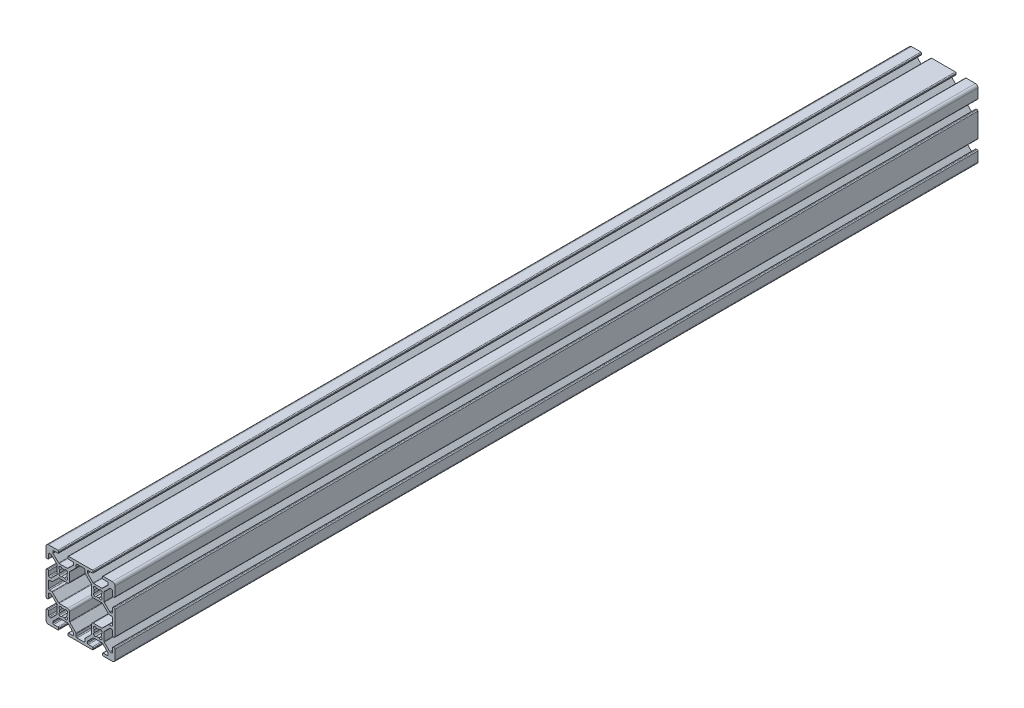
from build123d import *

# Parameters (mm, degrees)
EXTRUDE1_DEPTH = 500


with BuildPart() as part:
    # Sketch1 → Extrude1 (new body)
    with BuildSketch(Plane.XY):
        with BuildLine():
            Line((-22.383919339, -3.655), (-17.616080661, -3.655))
            ThreePointArc((-17.616080661, -3.655), (-17.421677478, -3.693669197), (-17.256870417, -3.803789755))
            Line((-17.256870417, -3.803789755), (-14.153789755, -6.906870417))
            ThreePointArc((-14.153789755, -6.906870417), (-14.043669197, -7.071677478), (-14.005, -7.266080661))
            Line((-14.005, -7.266080661), (-14.005, -7.992))
            ThreePointArc((-14.005, -7.992), (-14.153789755, -8.351210245), (-14.513, -8.5))
            Line((-14.513, -8.5), (-16.862, -8.5))
            ThreePointArc((-16.862, -8.5), (-17.221210245, -8.648789755), (-17.37, -9.008))
            Line((-17.37, -9.008), (-17.37, -9.492))
            ThreePointArc((-17.37, -9.492), (-17.221210245, -9.851210245), (-16.862, -10))
            Line((-16.862, -10), (-3.138, -10))
            ThreePointArc((-3.138, -10), (-2.778789755, -9.851210245), (-2.63, -9.492))
            Line((-2.63, -9.492), (-2.63, -9.008))
            ThreePointArc((-2.63, -9.008), (-2.778789755, -8.648789755), (-3.138, -8.5))
            Line((-3.138, -8.5), (-5.487, -8.5))
            ThreePointArc((-5.487, -8.5), (-5.846210245, -8.351210245), (-5.995, -7.992))
            Line((-5.995, -7.992), (-5.995, -7.266080661))
            ThreePointArc((-5.995, -7.266080661), (-5.956330803, -7.071677478), (-5.846210245, -6.906870417))
            Line((-5.846210245, -6.906870417), (-2.743129583, -3.803789755))
            ThreePointArc((-2.743129583, -3.803789755), (-2.578322522, -3.693669197), (-2.383919339, -3.655))
            Line((-2.383919339, -3.655), (2.383919339, -3.655))
            ThreePointArc((2.383919339, -3.655), (2.578322522, -3.693669197), (2.743129583, -3.803789755))
            Line((2.743129583, -3.803789755), (5.846210245, -6.906870417))
            ThreePointArc((5.846210245, -6.906870417), (5.956330803, -7.071677478), (5.995, -7.266080661))
            Line((5.995, -7.266080661), (5.995, -7.992))
            ThreePointArc((5.995, -7.992), (5.846210245, -8.351210245), (5.487, -8.5))
            Line((5.487, -8.5), (3.138, -8.5))
            ThreePointArc((3.138, -8.5), (2.778789755, -8.648789755), (2.63, -9.008))
            Line((2.63, -9.008), (2.63, -9.492))
            ThreePointArc((2.63, -9.492), (2.778789755, -9.851210245), (3.138, -10))
            Line((3.138, -10), (8.5, -10))
            ThreePointArc((8.5, -10), (9.560660172, -9.560660172), (10, -8.5))
            Line((10, -8.5), (10, -3.138))
            ThreePointArc((10, -3.138), (9.851210245, -2.778789755), (9.492, -2.63))
            Line((9.492, -2.63), (9.008, -2.63))
            ThreePointArc((9.008, -2.63), (8.648789755, -2.778789755), (8.5, -3.138))
            Line((8.5, -3.138), (8.5, -5.487))
            ThreePointArc((8.5, -5.487), (8.351210245, -5.846210245), (7.992, -5.995))
            Line((7.992, -5.995), (7.266080661, -5.995))
            ThreePointArc((7.266080661, -5.995), (7.071677478, -5.956330803), (6.906870417, -5.846210245))
            Line((6.906870417, -5.846210245), (3.803789755, -2.743129583))
            ThreePointArc((3.803789755, -2.743129583), (3.693669197, -2.578322522), (3.655, -2.383919339))
            Line((3.655, -2.383919339), (3.655, 2.383919339))
            ThreePointArc((3.655, 2.383919339), (3.693669197, 2.578322522), (3.803789755, 2.743129583))
            Line((3.803789755, 2.743129583), (6.906870417, 5.846210245))
            ThreePointArc((6.906870417, 5.846210245), (7.071677478, 5.956330803), (7.266080661, 5.995))
            Line((7.266080661, 5.995), (7.992, 5.995))
            ThreePointArc((7.992, 5.995), (8.351210245, 5.846210245), (8.5, 5.487))
            Line((8.5, 5.487), (8.5, 3.138))
            ThreePointArc((8.5, 3.138), (8.648789755, 2.778789755), (9.008, 2.63))
            Line((9.008, 2.63), (9.492, 2.63))
            ThreePointArc((9.492, 2.63), (9.851210245, 2.778789755), (10, 3.138))
            Line((10, 3.138), (10, 16.862))
            ThreePointArc((10, 16.862), (9.851210245, 17.221210245), (9.492, 17.37))
            Line((9.492, 17.37), (9.008, 17.37))
            ThreePointArc((9.008, 17.37), (8.648789755, 17.221210245), (8.5, 16.862))
            Line((8.5, 16.862), (8.5, 14.513))
            ThreePointArc((8.5, 14.513), (8.351210245, 14.153789755), (7.992, 14.005))
            Line((7.992, 14.005), (7.266080661, 14.005))
            ThreePointArc((7.266080661, 14.005), (7.071677478, 14.043669197), (6.906870417, 14.153789755))
            Line((6.906870417, 14.153789755), (3.803789755, 17.256870417))
            ThreePointArc((3.803789755, 17.256870417), (3.693669197, 17.421677478), (3.655, 17.616080661))
            Line((3.655, 17.616080661), (3.655, 22.383919339))
            ThreePointArc((3.655, 22.383919339), (3.693669197, 22.578322522), (3.803789755, 22.743129583))
            Line((3.803789755, 22.743129583), (6.906870417, 25.846210245))
            ThreePointArc((6.906870417, 25.846210245), (7.071677478, 25.956330803), (7.266080661, 25.995))
            Line((7.266080661, 25.995), (7.992, 25.995))
            ThreePointArc((7.992, 25.995), (8.351210245, 25.846210245), (8.5, 25.487))
            Line((8.5, 25.487), (8.5, 23.138))
            ThreePointArc((8.5, 23.138), (8.648789755, 22.778789755), (9.008, 22.63))
            Line((9.008, 22.63), (9.492, 22.63))
            ThreePointArc((9.492, 22.63), (9.851210245, 22.778789755), (10, 23.138))
            Line((10, 23.138), (10, 28.5))
            ThreePointArc((10, 28.5), (9.560660172, 29.560660172), (8.5, 30))
            Line((8.5, 30), (3.138, 30))
            ThreePointArc((3.138, 30), (2.778789755, 29.851210245), (2.63, 29.492))
            Line((2.63, 29.492), (2.63, 29.008))
            ThreePointArc((2.63, 29.008), (2.778789755, 28.648789755), (3.138, 28.5))
            Line((3.138, 28.5), (5.487, 28.5))
            ThreePointArc((5.487, 28.5), (5.846210245, 28.351210245), (5.995, 27.992))
            Line((5.995, 27.992), (5.995, 27.266080661))
            ThreePointArc((5.995, 27.266080661), (5.956330803, 27.071677478), (5.846210245, 26.906870417))
            Line((5.846210245, 26.906870417), (2.743129583, 23.803789755))
            ThreePointArc((2.743129583, 23.803789755), (2.578322522, 23.693669197), (2.383919339, 23.655))
            Line((2.383919339, 23.655), (-2.383919339, 23.655))
            ThreePointArc((-2.383919339, 23.655), (-2.578322522, 23.693669197), (-2.743129583, 23.803789755))
            Line((-2.743129583, 23.803789755), (-5.846210245, 26.906870417))
            ThreePointArc((-5.846210245, 26.906870417), (-5.956330803, 27.071677478), (-5.995, 27.266080661))
            Line((-5.995, 27.266080661), (-5.995, 27.992))
            ThreePointArc((-5.995, 27.992), (-5.846210245, 28.351210245), (-5.487, 28.5))
            Line((-5.487, 28.5), (-3.138, 28.5))
            ThreePointArc((-3.138, 28.5), (-2.778789755, 28.648789755), (-2.63, 29.008))
            Line((-2.63, 29.008), (-2.63, 29.492))
            ThreePointArc((-2.63, 29.492), (-2.778789755, 29.851210245), (-3.138, 30))
            Line((-3.138, 30), (-16.862, 30))
            ThreePointArc((-16.862, 30), (-17.221210245, 29.851210245), (-17.37, 29.492))
            Line((-17.37, 29.492), (-17.37, 29.008))
            ThreePointArc((-17.37, 29.008), (-17.221210245, 28.648789755), (-16.862, 28.5))
            Line((-16.862, 28.5), (-14.513, 28.5))
            ThreePointArc((-14.513, 28.5), (-14.153789755, 28.351210245), (-14.005, 27.992))
            Line((-14.005, 27.992), (-14.005, 27.266080661))
            ThreePointArc((-14.005, 27.266080661), (-14.043669197, 27.071677478), (-14.153789755, 26.906870417))
            Line((-14.153789755, 26.906870417), (-17.256870417, 23.803789755))
            ThreePointArc((-17.256870417, 23.803789755), (-17.421677478, 23.693669197), (-17.616080661, 23.655))
            Line((-17.616080661, 23.655), (-22.383919339, 23.655))
            ThreePointArc((-22.383919339, 23.655), (-22.578322522, 23.693669197), (-22.743129583, 23.803789755))
            Line((-22.743129583, 23.803789755), (-25.846210245, 26.906870417))
            ThreePointArc((-25.846210245, 26.906870417), (-25.956330803, 27.071677478), (-25.995, 27.266080661))
            Line((-25.995, 27.266080661), (-25.995, 27.992))
            ThreePointArc((-25.995, 27.992), (-25.846210245, 28.351210245), (-25.487, 28.5))
            Line((-25.487, 28.5), (-23.138, 28.5))
            ThreePointArc((-23.138, 28.5), (-22.778789755, 28.648789755), (-22.63, 29.008))
            Line((-22.63, 29.008), (-22.63, 29.492))
            ThreePointArc((-22.63, 29.492), (-22.778789755, 29.851210245), (-23.138, 30))
            Line((-23.138, 30), (-28.5, 30))
            ThreePointArc((-28.5, 30), (-29.560660172, 29.560660172), (-30, 28.5))
            Line((-30, 28.5), (-30, 23.138))
            ThreePointArc((-30, 23.138), (-29.851210245, 22.778789755), (-29.492, 22.63))
            Line((-29.492, 22.63), (-29.008, 22.63))
            ThreePointArc((-29.008, 22.63), (-28.648789755, 22.778789755), (-28.5, 23.138))
            Line((-28.5, 23.138), (-28.5, 25.487))
            ThreePointArc((-28.5, 25.487), (-28.351210245, 25.846210245), (-27.992, 25.995))
            Line((-27.992, 25.995), (-27.266080661, 25.995))
            ThreePointArc((-27.266080661, 25.995), (-27.071677478, 25.956330803), (-26.906870417, 25.846210245))
            Line((-26.906870417, 25.846210245), (-23.803789755, 22.743129583))
            ThreePointArc((-23.803789755, 22.743129583), (-23.693669197, 22.578322522), (-23.655, 22.383919339))
            Line((-23.655, 22.383919339), (-23.655, 17.616080661))
            ThreePointArc((-23.655, 17.616080661), (-23.693669197, 17.421677478), (-23.803789755, 17.256870417))
            Line((-23.803789755, 17.256870417), (-26.906870417, 14.153789755))
            ThreePointArc((-26.906870417, 14.153789755), (-27.071677478, 14.043669197), (-27.266080661, 14.005))
            Line((-27.266080661, 14.005), (-27.992, 14.005))
            ThreePointArc((-27.992, 14.005), (-28.351210245, 14.153789755), (-28.5, 14.513))
            Line((-28.5, 14.513), (-28.5, 16.862))
            ThreePointArc((-28.5, 16.862), (-28.648789755, 17.221210245), (-29.008, 17.37))
            Line((-29.008, 17.37), (-29.492, 17.37))
            ThreePointArc((-29.492, 17.37), (-29.851210245, 17.221210245), (-30, 16.862))
            Line((-30, 16.862), (-30, 3.138))
            ThreePointArc((-30, 3.138), (-29.851210245, 2.778789755), (-29.492, 2.63))
            Line((-29.492, 2.63), (-29.008, 2.63))
            ThreePointArc((-29.008, 2.63), (-28.648789755, 2.778789755), (-28.5, 3.138))
            Line((-28.5, 3.138), (-28.5, 5.487))
            ThreePointArc((-28.5, 5.487), (-28.351210245, 5.846210245), (-27.992, 5.995))
            Line((-27.992, 5.995), (-27.266080661, 5.995))
            ThreePointArc((-27.266080661, 5.995), (-27.071677478, 5.956330803), (-26.906870417, 5.846210245))
            Line((-26.906870417, 5.846210245), (-23.803789755, 2.743129583))
            ThreePointArc((-23.803789755, 2.743129583), (-23.693669197, 2.578322522), (-23.655, 2.383919339))
            Line((-23.655, 2.383919339), (-23.655, -2.383919339))
            ThreePointArc((-23.655, -2.383919339), (-23.693669197, -2.578322522), (-23.803789755, -2.743129583))
            Line((-23.803789755, -2.743129583), (-26.906870417, -5.846210245))
            ThreePointArc((-26.906870417, -5.846210245), (-27.071677478, -5.956330803), (-27.266080661, -5.995))
            Line((-27.266080661, -5.995), (-27.992, -5.995))
            ThreePointArc((-27.992, -5.995), (-28.351210245, -5.846210245), (-28.5, -5.487))
            Line((-28.5, -5.487), (-28.5, -3.138))
            ThreePointArc((-28.5, -3.138), (-28.648789755, -2.778789755), (-29.008, -2.63))
            Line((-29.008, -2.63), (-29.492, -2.63))
            ThreePointArc((-29.492, -2.63), (-29.851210245, -2.778789755), (-30, -3.138))
            Line((-30, -3.138), (-30, -8.5))
            ThreePointArc((-30, -8.5), (-29.560660172, -9.560660172), (-28.5, -10))
            Line((-28.5, -10), (-23.138, -10))
            ThreePointArc((-23.138, -10), (-22.778789755, -9.851210245), (-22.63, -9.492))
            Line((-22.63, -9.492), (-22.63, -9.008))
            ThreePointArc((-22.63, -9.008), (-22.778789755, -8.648789755), (-23.138, -8.5))
            Line((-23.138, -8.5), (-25.487, -8.5))
            ThreePointArc((-25.487, -8.5), (-25.846210245, -8.351210245), (-25.995, -7.992))
            Line((-25.995, -7.992), (-25.995, -7.266080661))
            ThreePointArc((-25.995, -7.266080661), (-25.956330803, -7.071677478), (-25.846210245, -6.906870417))
            Line((-25.846210245, -6.906870417), (-22.743129583, -3.803789755))
            ThreePointArc((-22.743129583, -3.803789755), (-22.578322522, -3.693669197), (-22.383919339, -3.655))
        make_face()
        with BuildLine():
            Line((-2.124900844, 17.695494034), (-2.304505966, 17.875099156))
            ThreePointArc((-2.304505966, 17.875099156), (-2.505938017, 18.643532189), (-1.935133506, 19.196023282))
            ThreePointArc((-1.935133506, 19.196023282), (-2.0955, 20), (-1.935133506, 20.803976718))
            ThreePointArc((-1.935133506, 20.803976718), (-2.505938017, 21.356467811), (-2.304505966, 22.124900844))
            Line((-2.304505966, 22.124900844), (-2.124900844, 22.304505966))
            ThreePointArc((-2.124900844, 22.304505966), (-1.356467811, 22.505938017), (-0.803976718, 21.935133506))
            ThreePointArc((-0.803976718, 21.935133506), (0, 22.0955), (0.803976718, 21.935133506))
            ThreePointArc((0.803976718, 21.935133506), (1.356467811, 22.505938017), (2.124900844, 22.304505966))
            Line((2.124900844, 22.304505966), (2.304505966, 22.124900844))
            ThreePointArc((2.304505966, 22.124900844), (2.505938017, 21.356467811), (1.935133506, 20.803976718))
            ThreePointArc((1.935133506, 20.803976718), (2.0955, 20), (1.935133506, 19.196023282))
            ThreePointArc((1.935133506, 19.196023282), (2.505938017, 18.643532189), (2.304505966, 17.875099156))
            Line((2.304505966, 17.875099156), (2.124900844, 17.695494034))
            ThreePointArc((2.124900844, 17.695494034), (1.356467811, 17.494061983), (0.803976718, 18.064866494))
            ThreePointArc((0.803976718, 18.064866494), (0, 17.9045), (-0.803976718, 18.064866494))
            ThreePointArc((-0.803976718, 18.064866494), (-1.356467811, 17.494061983), (-2.124900844, 17.695494034))
        make_face(mode=Mode.SUBTRACT)
        with BuildLine():
            Line((-22.124900844, 17.695494034), (-22.304505966, 17.875099156))
            ThreePointArc((-22.304505966, 17.875099156), (-22.505938017, 18.643532189), (-21.935133506, 19.196023282))
            ThreePointArc((-21.935133506, 19.196023282), (-22.0955, 20), (-21.935133506, 20.803976718))
            ThreePointArc((-21.935133506, 20.803976718), (-22.505938017, 21.356467811), (-22.304505966, 22.124900844))
            Line((-22.304505966, 22.124900844), (-22.124900844, 22.304505966))
            ThreePointArc((-22.124900844, 22.304505966), (-21.356467811, 22.505938017), (-20.803976718, 21.935133506))
            ThreePointArc((-20.803976718, 21.935133506), (-20, 22.0955), (-19.196023282, 21.935133506))
            ThreePointArc((-19.196023282, 21.935133506), (-18.643532189, 22.505938017), (-17.875099156, 22.304505966))
            Line((-17.875099156, 22.304505966), (-17.695494034, 22.124900844))
            ThreePointArc((-17.695494034, 22.124900844), (-17.494061983, 21.356467811), (-18.064866494, 20.803976718))
            ThreePointArc((-18.064866494, 20.803976718), (-17.9045, 20), (-18.064866494, 19.196023282))
            ThreePointArc((-18.064866494, 19.196023282), (-17.494061983, 18.643532189), (-17.695494034, 17.875099156))
            Line((-17.695494034, 17.875099156), (-17.875099156, 17.695494034))
            ThreePointArc((-17.875099156, 17.695494034), (-18.643532189, 17.494061983), (-19.196023282, 18.064866494))
            ThreePointArc((-19.196023282, 18.064866494), (-20, 17.9045), (-20.803976718, 18.064866494))
            ThreePointArc((-20.803976718, 18.064866494), (-21.356467811, 17.494061983), (-22.124900844, 17.695494034))
        make_face(mode=Mode.SUBTRACT)
        with BuildLine():
            Line((-2.124900844, -2.304505966), (-2.304505966, -2.124900844))
            ThreePointArc((-2.304505966, -2.124900844), (-2.505938017, -1.356467811), (-1.935133506, -0.803976718))
            ThreePointArc((-1.935133506, -0.803976718), (-2.0955, 0), (-1.935133506, 0.803976718))
            ThreePointArc((-1.935133506, 0.803976718), (-2.505938017, 1.356467811), (-2.304505966, 2.124900844))
            Line((-2.304505966, 2.124900844), (-2.124900844, 2.304505966))
            ThreePointArc((-2.124900844, 2.304505966), (-1.356467811, 2.505938017), (-0.803976718, 1.935133506))
            ThreePointArc((-0.803976718, 1.935133506), (0, 2.0955), (0.803976718, 1.935133506))
            ThreePointArc((0.803976718, 1.935133506), (1.356467811, 2.505938017), (2.124900844, 2.304505966))
            Line((2.124900844, 2.304505966), (2.304505966, 2.124900844))
            ThreePointArc((2.304505966, 2.124900844), (2.505938017, 1.356467811), (1.935133506, 0.803976718))
            ThreePointArc((1.935133506, 0.803976718), (2.0955, 0), (1.935133506, -0.803976718))
            ThreePointArc((1.935133506, -0.803976718), (2.505938017, -1.356467811), (2.304505966, -2.124900844))
            Line((2.304505966, -2.124900844), (2.124900844, -2.304505966))
            ThreePointArc((2.124900844, -2.304505966), (1.356467811, -2.505938017), (0.803976718, -1.935133506))
            ThreePointArc((0.803976718, -1.935133506), (0, -2.0955), (-0.803976718, -1.935133506))
            ThreePointArc((-0.803976718, -1.935133506), (-1.356467811, -2.505938017), (-2.124900844, -2.304505966))
        make_face(mode=Mode.SUBTRACT)
        with BuildLine():
            Line((-12.505, -7.992), (-12.505, -6.644760318))
            ThreePointArc((-12.505, -6.644760318), (-12.543669197, -6.450357134), (-12.653789755, -6.285550073))
            Line((-12.653789755, -6.285550073), (-16.196210245, -2.743129583))
            ThreePointArc((-16.196210245, -2.743129583), (-16.306330803, -2.578322522), (-16.345, -2.383919339))
            Line((-16.345, -2.383919339), (-16.345, 2.512))
            ThreePointArc((-16.345, 2.512), (-16.679776949, 3.320223051), (-17.488, 3.655))
            Line((-17.488, 3.655), (-22.383919339, 3.655))
            ThreePointArc((-22.383919339, 3.655), (-22.578322522, 3.693669197), (-22.743129583, 3.803789755))
            Line((-22.743129583, 3.803789755), (-26.285550073, 7.346210245))
            ThreePointArc((-26.285550073, 7.346210245), (-26.450357134, 7.456330803), (-26.644760318, 7.495))
            Line((-26.644760318, 7.495), (-27.992, 7.495))
            ThreePointArc((-27.992, 7.495), (-28.351210245, 7.643789755), (-28.5, 8.003))
            Line((-28.5, 8.003), (-28.5, 11.997))
            ThreePointArc((-28.5, 11.997), (-28.351210245, 12.356210245), (-27.992, 12.505))
            Line((-27.992, 12.505), (-26.644760318, 12.505))
            ThreePointArc((-26.644760318, 12.505), (-26.450357134, 12.543669197), (-26.285550073, 12.653789755))
            Line((-26.285550073, 12.653789755), (-22.743129583, 16.196210245))
            ThreePointArc((-22.743129583, 16.196210245), (-22.578322522, 16.306330803), (-22.383919339, 16.345))
            Line((-22.383919339, 16.345), (-17.488, 16.345))
            ThreePointArc((-17.488, 16.345), (-16.679776949, 16.679776949), (-16.345, 17.488))
            Line((-16.345, 17.488), (-16.345, 22.383919339))
            ThreePointArc((-16.345, 22.383919339), (-16.306330803, 22.578322522), (-16.196210245, 22.743129583))
            Line((-16.196210245, 22.743129583), (-12.653789755, 26.285550073))
            ThreePointArc((-12.653789755, 26.285550073), (-12.543669197, 26.450357134), (-12.505, 26.644760318))
            Line((-12.505, 26.644760318), (-12.505, 27.992))
            ThreePointArc((-12.505, 27.992), (-12.356210245, 28.351210245), (-11.997, 28.5))
            Line((-11.997, 28.5), (-8.003, 28.5))
            ThreePointArc((-8.003, 28.5), (-7.643789755, 28.351210245), (-7.495, 27.992))
            Line((-7.495, 27.992), (-7.495, 26.644760318))
            ThreePointArc((-7.495, 26.644760318), (-7.456330803, 26.450357134), (-7.346210245, 26.285550073))
            Line((-7.346210245, 26.285550073), (-3.803789755, 22.743129583))
            ThreePointArc((-3.803789755, 22.743129583), (-3.693669197, 22.578322522), (-3.655, 22.383919339))
            Line((-3.655, 22.383919339), (-3.655, 17.488))
            ThreePointArc((-3.655, 17.488), (-3.320223051, 16.679776949), (-2.512, 16.345))
            Line((-2.512, 16.345), (2.383919339, 16.345))
            ThreePointArc((2.383919339, 16.345), (2.578322522, 16.306330803), (2.743129583, 16.196210245))
            Line((2.743129583, 16.196210245), (6.285550073, 12.653789755))
            ThreePointArc((6.285550073, 12.653789755), (6.450357134, 12.543669197), (6.644760318, 12.505))
            Line((6.644760318, 12.505), (7.992, 12.505))
            ThreePointArc((7.992, 12.505), (8.351210245, 12.356210245), (8.5, 11.997))
            Line((8.5, 11.997), (8.5, 8.003))
            ThreePointArc((8.5, 8.003), (8.351210245, 7.643789755), (7.992, 7.495))
            Line((7.992, 7.495), (6.644760318, 7.495))
            ThreePointArc((6.644760318, 7.495), (6.450357134, 7.456330803), (6.285550073, 7.346210245))
            Line((6.285550073, 7.346210245), (2.743129583, 3.803789755))
            ThreePointArc((2.743129583, 3.803789755), (2.578322522, 3.693669197), (2.383919339, 3.655))
            Line((2.383919339, 3.655), (-2.512, 3.655))
            ThreePointArc((-2.512, 3.655), (-3.320223051, 3.320223051), (-3.655, 2.512))
            Line((-3.655, 2.512), (-3.655, -2.383919339))
            ThreePointArc((-3.655, -2.383919339), (-3.693669197, -2.578322522), (-3.803789755, -2.743129583))
            Line((-3.803789755, -2.743129583), (-7.346210245, -6.285550073))
            ThreePointArc((-7.346210245, -6.285550073), (-7.456330803, -6.450357134), (-7.495, -6.644760318))
            Line((-7.495, -6.644760318), (-7.495, -7.992))
            ThreePointArc((-7.495, -7.992), (-7.643789755, -8.351210245), (-8.003, -8.5))
            Line((-8.003, -8.5), (-11.997, -8.5))
            ThreePointArc((-11.997, -8.5), (-12.356210245, -8.351210245), (-12.505, -7.992))
        make_face(mode=Mode.SUBTRACT)
        with BuildLine():
            Line((-22.124900844, -2.304505966), (-22.304505966, -2.124900844))
            ThreePointArc((-22.304505966, -2.124900844), (-22.505938017, -1.356467811), (-21.935133506, -0.803976718))
            ThreePointArc((-21.935133506, -0.803976718), (-22.0955, 0), (-21.935133506, 0.803976718))
            ThreePointArc((-21.935133506, 0.803976718), (-22.505938017, 1.356467811), (-22.304505966, 2.124900844))
            Line((-22.304505966, 2.124900844), (-22.124900844, 2.304505966))
            ThreePointArc((-22.124900844, 2.304505966), (-21.356467811, 2.505938017), (-20.803976718, 1.935133506))
            ThreePointArc((-20.803976718, 1.935133506), (-20, 2.0955), (-19.196023282, 1.935133506))
            ThreePointArc((-19.196023282, 1.935133506), (-18.643532189, 2.505938017), (-17.875099156, 2.304505966))
            Line((-17.875099156, 2.304505966), (-17.695494034, 2.124900844))
            ThreePointArc((-17.695494034, 2.124900844), (-17.494061983, 1.356467811), (-18.064866494, 0.803976718))
            ThreePointArc((-18.064866494, 0.803976718), (-17.9045, 0), (-18.064866494, -0.803976718))
            ThreePointArc((-18.064866494, -0.803976718), (-17.494061983, -1.356467811), (-17.695494034, -2.124900844))
            Line((-17.695494034, -2.124900844), (-17.875099156, -2.304505966))
            ThreePointArc((-17.875099156, -2.304505966), (-18.643532189, -2.505938017), (-19.196023282, -1.935133506))
            ThreePointArc((-19.196023282, -1.935133506), (-20, -2.0955), (-20.803976718, -1.935133506))
            ThreePointArc((-20.803976718, -1.935133506), (-21.356467811, -2.505938017), (-22.124900844, -2.304505966))
        make_face(mode=Mode.SUBTRACT)
    extrude(amount=-EXTRUDE1_DEPTH)


solid = part.part
